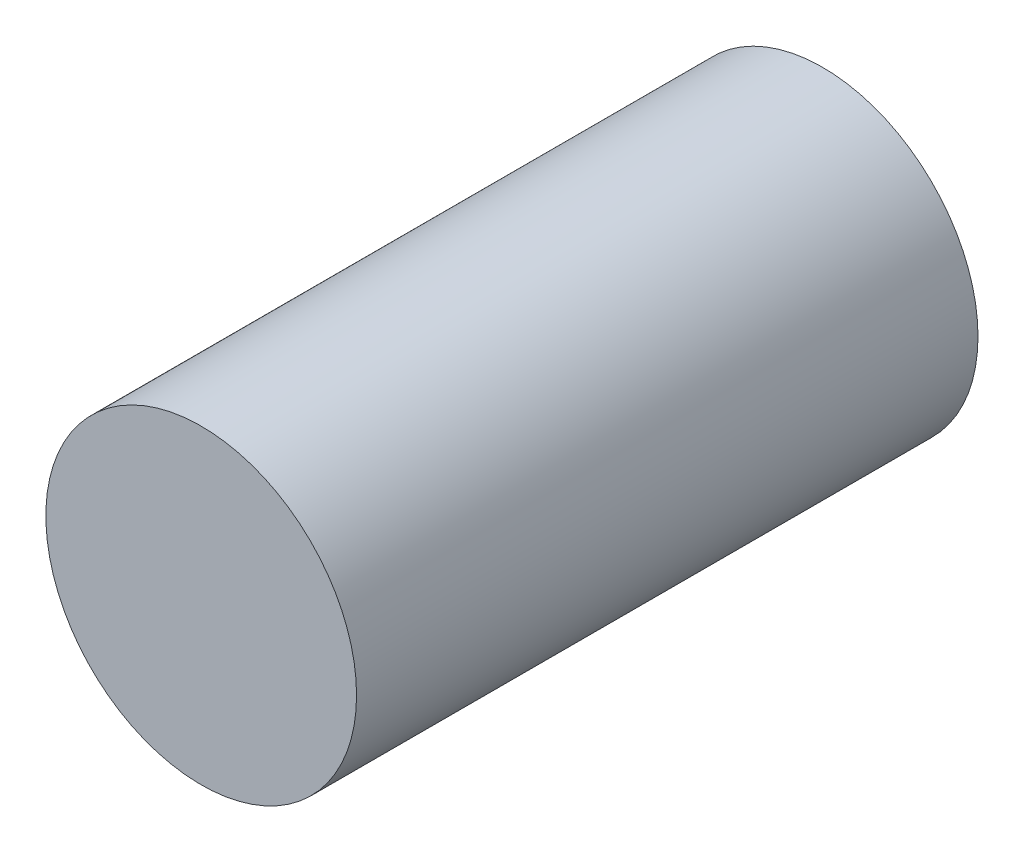
from build123d import *

# Parameters (mm, degrees)
SKETCH_1_R      = 1
EXTRUDE_1_DEPTH = 4


with BuildPart() as part:
    # 草图1 → 凸台-拉伸1 (new body)
    with BuildSketch(Plane.XY):
        Circle(SKETCH_1_R)
    extrude(amount=EXTRUDE_1_DEPTH)


solid = part.part
